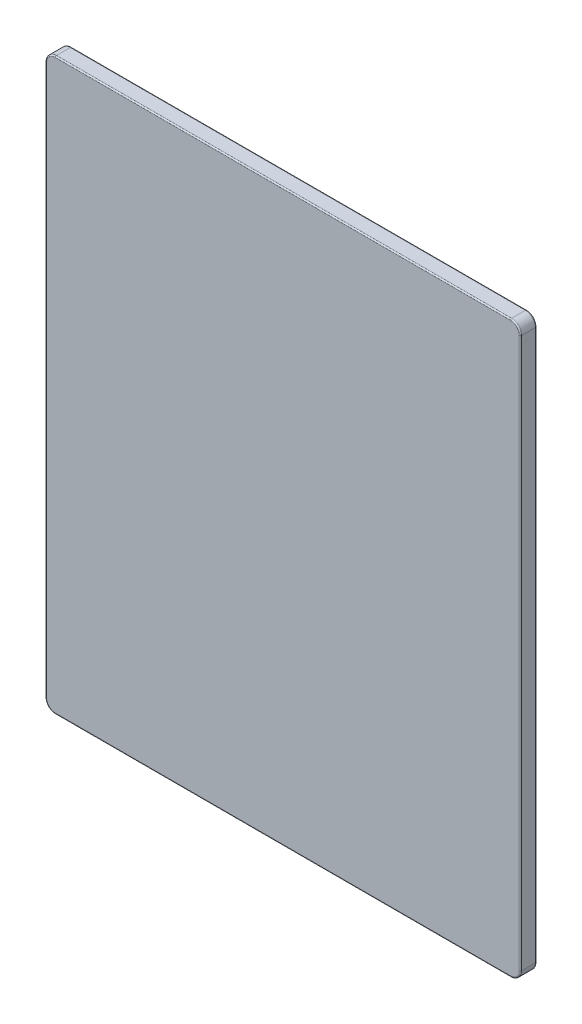
from build123d import *

# Parameters (mm, degrees)
SKETCH1_W           = 381
SKETCH1_H           = 457.2
BOSS_EXTRUDE1_DEPTH = 13
FILLET1_R           = 8
FILLET2_R           = 1


with BuildPart() as part:
    # Sketch1 → Boss-Extrude1 (new body)
    with BuildSketch(Plane.XY):
        Rectangle(SKETCH1_W, SKETCH1_H)
    extrude(amount=BOSS_EXTRUDE1_DEPTH)

    # Fillet1
    fillet1_edges = [part.edges().sort_by_distance(p)[0] for p in [
        (190.5, -228.6, 6.5),
        (-190.5, -228.6, 6.5),
        (-190.5, 228.6, 6.5),
        (190.5, 228.6, 6.5),
    ]]
    fillet(fillet1_edges, radius=FILLET1_R)

    # Fillet2
    fillet2_edges = [part.edges().sort_by_distance(p)[0] for p in [
        (0, 228.6, 0),
        (0, 228.6, 13),
        (190.5, 0, 0),
        (0, -228.6, 0),
        (-190.5, 0, 0),
        (-188.156854249, -226.256854249, 0),
        (188.156854249, -226.256854249, 0),
        (-188.156854249, 226.256854249, 0),
        (188.156854249, 226.256854249, 0),
        (190.5, 0, 13),
        (-190.5, 0, 13),
        (0, -228.6, 13),
        (-188.156854249, -226.256854249, 13),
        (188.156854249, -226.256854249, 13),
        (-188.156854249, 226.256854249, 13),
        (188.156854249, 226.256854249, 13),
    ]]
    fillet(fillet2_edges, radius=FILLET2_R)


solid = part.part
